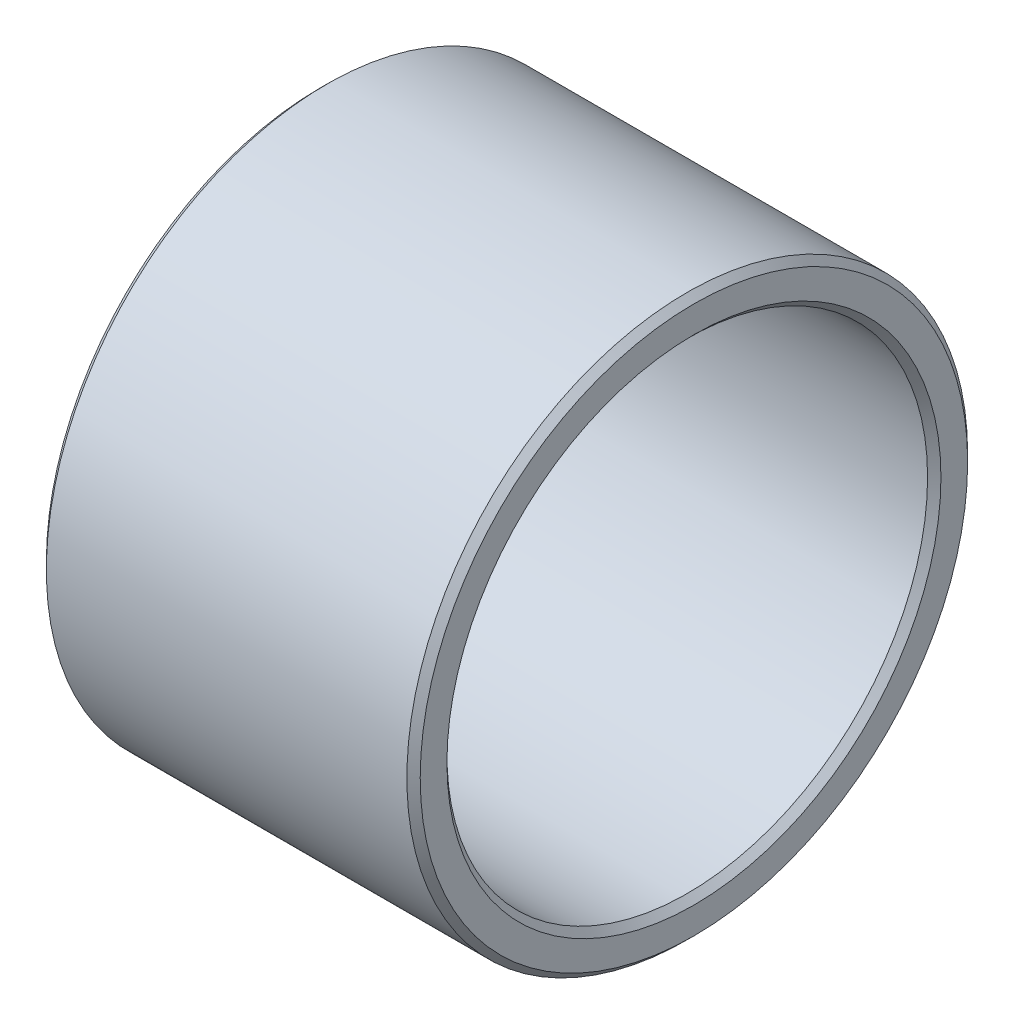
from build123d import *

# Parameters (mm, degrees)
SKETCH_1_R      = 21
SKETCH_1_R_2    = 18
EXTRUDE_1_DEPTH = 28
CHAMFER_1_SIZE  = 0.5


with BuildPart() as part:
    # 草图1 → 凸台-拉伸1 (new body)
    with BuildSketch(Plane(origin=(0, 0, 0), x_dir=(0, 0, -1), z_dir=(1, 0, 0))):
        Circle(SKETCH_1_R)
        Circle(SKETCH_1_R_2, mode=Mode.SUBTRACT)
    extrude(amount=EXTRUDE_1_DEPTH)

    # 倒角1
    chamfer_1_edges = [part.edges().sort_by_distance(p)[0] for p in [
        (0, 0, 21),
        (28, 0, 21),
        (0, 0, 18),
        (28, 0, 18),
    ]]
    chamfer(chamfer_1_edges, length=CHAMFER_1_SIZE)


solid = part.part
